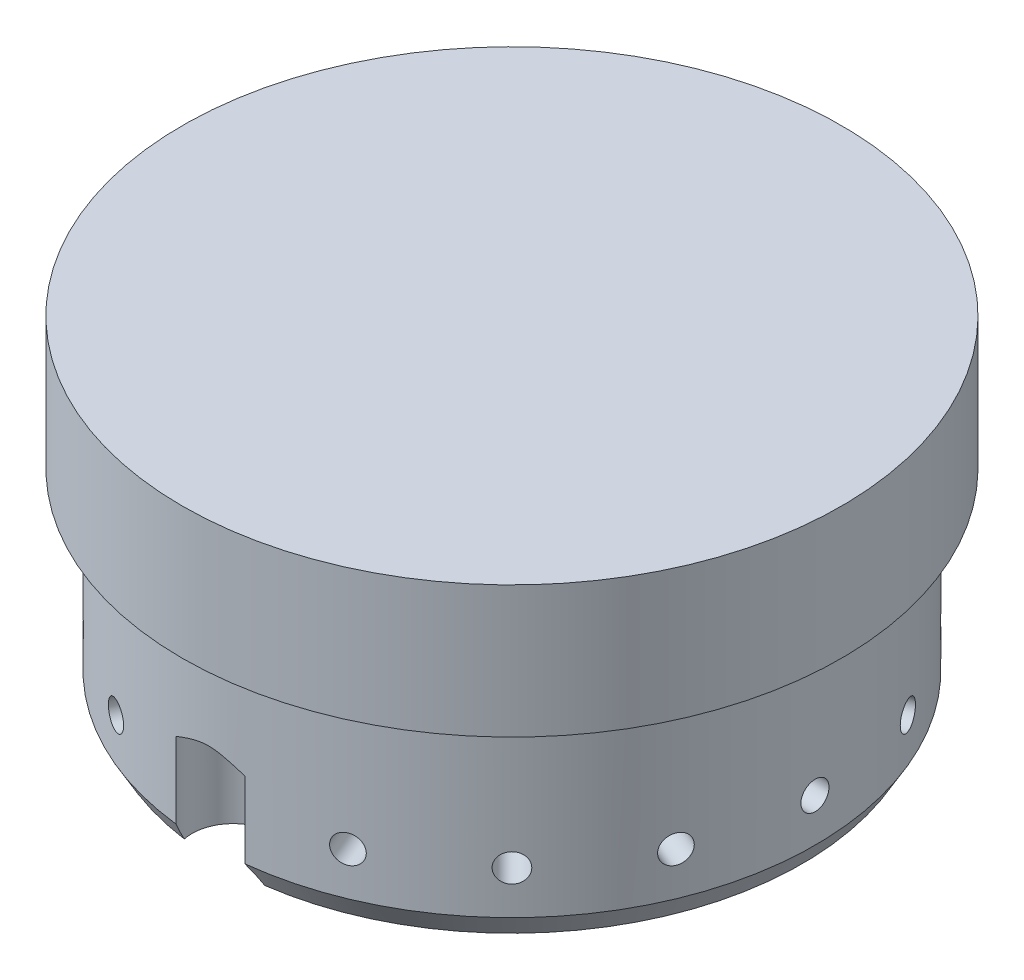
from build123d import *

# Parameters (mm, degrees)
TAP_PATTERN_COUNT                = 16
CHAMFER1_SIZE                    = 2.54
CHAMFER1_SIZE2                   = 4.399409051
F_5_8_0_625_DIAMETER_HOLE1_D     = 15.875
F_5_8_0_625_DIAMETER_HOLE1_DEPTH = 19.05
F_5_8_0_625_DIAMETER_HOLE1_TIP   = 4.769331164


with BuildPart() as part:
    # Sketch1 → Revolve1 (revolve)
    with BuildSketch(Plane.XY):
        Polygon((0, 0), (-58.4454, 0), (-58.4454, 38.1), (-63.5, 38.1), (-63.5, 63.5), (0, 63.5), align=None)
    revolve(axis=Axis((0, 63.5, 0), (0, -1, 0)))

    # Sketch13 → 1/4-28 Tap (revolve, cut)
    with BuildSketch(Plane(origin=(0, 12.7, 58.4454), x_dir=(0, -1, 0), z_dir=(1, 0, 0))):
        Polygon((0, 0), (0, 20.675388061), (2.7051, 19.05), (2.7051, 0), align=None)
    f_1_4_28_tap = revolve(axis=Axis((0, 12.7, 64.7954), (0, 0, -1)), mode=Mode.SUBTRACT)

    # Tap Pattern: 1/4-28 Tap ×16 about axis
    tap_pattern_axis = Axis((0, 0, 0), (0, 1, 0))
    for i in range(1, TAP_PATTERN_COUNT):
        add(f_1_4_28_tap.rotate(tap_pattern_axis, i * 360 / TAP_PATTERN_COUNT), mode=Mode.SUBTRACT)

    # Chamfer1
    chamfer1_edges = [part.edges().sort_by_distance(p)[0] for p in [
        (58.4454, 0, 0),
    ]]
    chamfer1_side = [part.faces().sort_by_distance(p)[0] for p in [
        (0, 0, 0),
    ]]
    chamfer(chamfer1_edges, length=CHAMFER1_SIZE, length2=CHAMFER1_SIZE2, reference=chamfer1_side[0])

    # 5/8 (0.625) Diameter Hole1
    with Locations(Plane(origin=(0, 0, 0), x_dir=(-1, 0, 0), z_dir=(0, -1, 0))):
        with Locations((0, -53.6829), (0, 53.6829)):
            Hole(F_5_8_0_625_DIAMETER_HOLE1_D / 2, depth=F_5_8_0_625_DIAMETER_HOLE1_DEPTH)
            with Locations((0, 0, -(F_5_8_0_625_DIAMETER_HOLE1_DEPTH + F_5_8_0_625_DIAMETER_HOLE1_TIP / 2))):  # 118° drill point
                Cone(0, F_5_8_0_625_DIAMETER_HOLE1_D / 2, F_5_8_0_625_DIAMETER_HOLE1_TIP, mode=Mode.SUBTRACT)


solid = part.part
